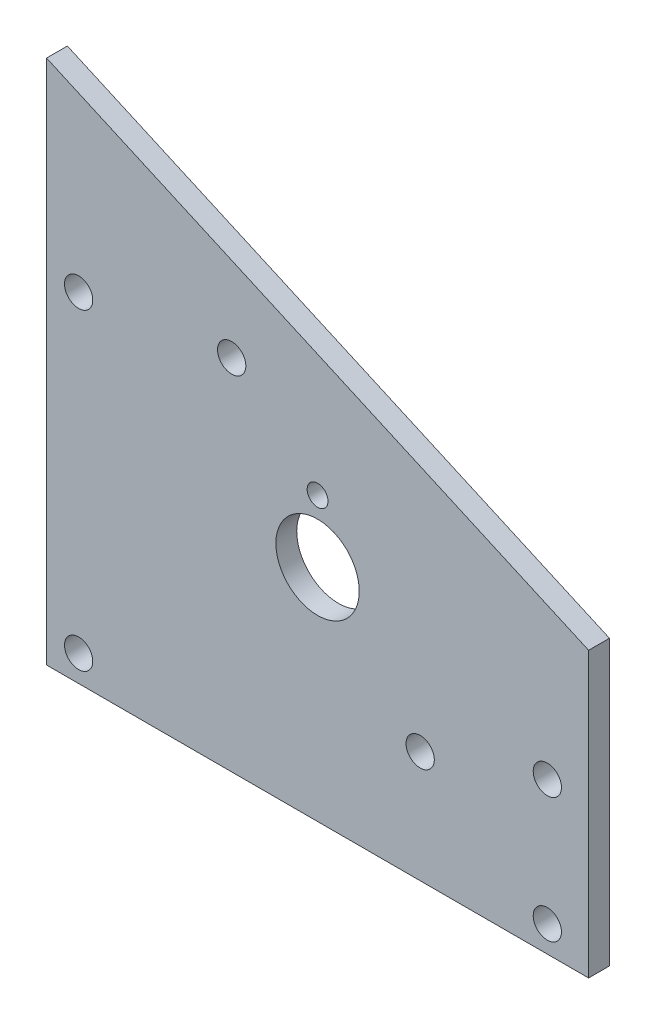
from build123d import *

# Parameters (mm, degrees)
BOSS_EXTRUDE1_DEPTH          = 3.175
F_6_CLEARANCE_HOLE1_D        = 4.3053
F_1_2_0_5_DIAMETER_HOLE1_D   = 12.7
F_1_8_0_125_DIAMETER_HOLE1_D = 3.175
CUT_EXTRUDE1_DEPTH           = 4.175
SKETCH10_W                   = 82.55
SKETCH10_H                   = 13.462
CUT_EXTRUDE2_DEPTH           = 4.175


with BuildPart() as part:
    # Sketch1 → Boss-Extrude1 (new body)
    with BuildSketch(Plane.XY):
        with BuildLine():
            Line((49.022, 13.462), (57.658, 13.462))
            ThreePointArc((57.658, 13.462), (61.250102448, 11.974102448), (62.738, 8.382))
            Line((62.738, 8.382), (62.738, 0))
            Line((62.738, 0), (82.55, 0))
            Line((82.55, 0), (82.55, 58.42))
            Line((82.55, 58.42), (0, 95.25))
            Line((0, 95.25), (0, 0))
            Line((0, 0), (43.942, 0))
            Line((43.942, 0), (43.942, 8.382))
            ThreePointArc((43.942, 8.382), (45.429897552, 11.974102448), (49.022, 13.462))
        make_face()
    extrude(amount=-BOSS_EXTRUDE1_DEPTH)

    # #6 Clearance Hole1 (through all)
    with Locations(Plane(origin=(0, 0, -3.175), x_dir=(-1, 0, 0), z_dir=(0, 0, -1))):
        with Locations((-4.8895, 17.4625), (-4.8895, 65.0875), (-76.2635, 36.5125), (-76.2635, 17.4625), (-28.194, 68.072), (-56.896, 30.48)):
            Hole(F_6_CLEARANCE_HOLE1_D / 2)

    # 1/2 (0.5) Diameter Hole1 (through all)
    with Locations(Plane(origin=(0, 0, -3.175), x_dir=(-1, 0, 0), z_dir=(0, 0, -1))):
        with Locations((-41.275, 46.99)):
            Hole(F_1_2_0_5_DIAMETER_HOLE1_D / 2)

    # 1/8 (0.125) Diameter Hole1 (through all)
    with Locations(Plane.XY):
        with Locations((41.275, 56.488873013)):
            Hole(F_1_8_0_125_DIAMETER_HOLE1_D / 2)

    # Sketch9 → Cut-Extrude1 (cut, through all)
    with BuildSketch(Plane.XY):
        Polygon((82.55, 56.681667019), (0, 93.511667019), (0, 95.25), (82.55, 58.42), align=None)
    extrude(amount=-CUT_EXTRUDE1_DEPTH, mode=Mode.SUBTRACT)

    # Sketch10 → Cut-Extrude2 (cut, through all)
    with BuildSketch(Plane.XY):
        with Locations((41.275, 6.731)):
            Rectangle(SKETCH10_W, SKETCH10_H)
    extrude(amount=-CUT_EXTRUDE2_DEPTH, mode=Mode.SUBTRACT)


solid = part.part
